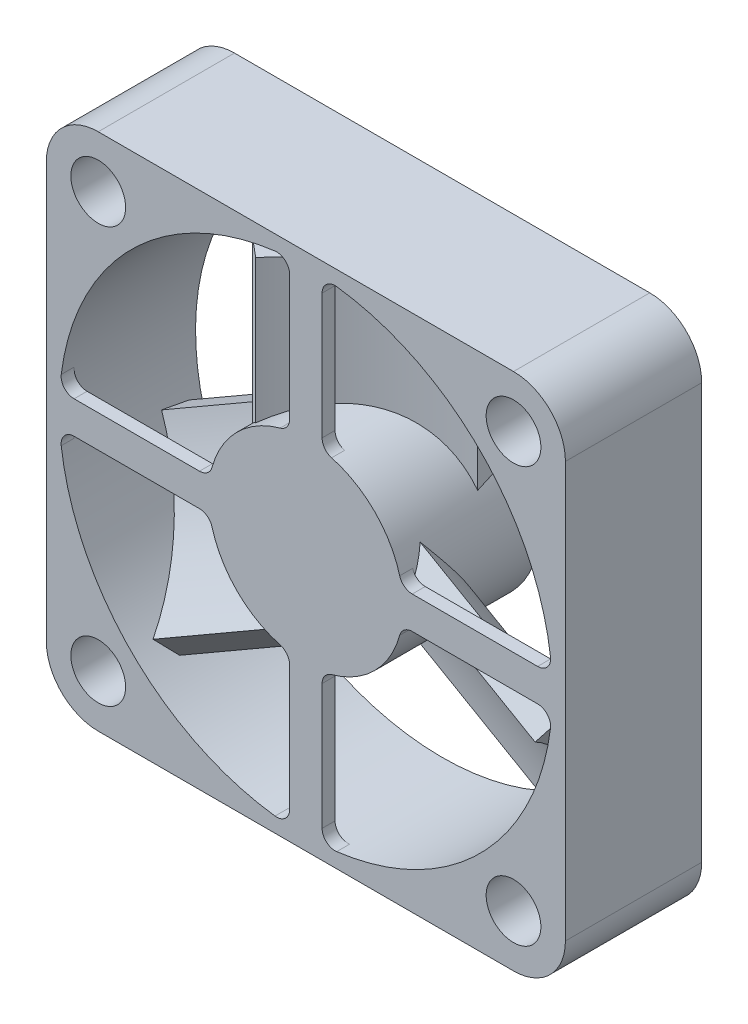
from build123d import *
from build123d.topology import SkipClean

# Parameters (mm, degrees)
SKETCH1_R           = 19
SKETCH1_R_2         = 2.11
BOSS_EXTRUDE1_DEPTH = 10.5
BOSS_EXTRUDE2_DEPTH = 1
CIRPATTERN1_COUNT   = 4
SKETCH4_R           = 7.5
BOSS_EXTRUDE3_DEPTH = 9.5
EXTRUDE_THIN1_DEPTH = 17
CIRPATTERN2_COUNT   = 3
CUT_EXTRUDE1_DEPTH  = 3.7
CIRPATTERN3_COUNT   = 4


with BuildPart() as part:
    # Sketch1 → Boss-Extrude1 (new body)
    with BuildSketch(Plane.XY):
        with BuildLine():
            Line((-16, 20), (16, 20))
            ThreePointArc((16, 20), (18.828427125, 18.828427125), (20, 16))
            Line((20, 16), (20, -16))
            ThreePointArc((20, -16), (18.828427125, -18.828427125), (16, -20))
            Line((16, -20), (-16, -20))
            ThreePointArc((-16, -20), (-18.828427125, -18.828427125), (-20, -16))
            Line((-20, -16), (-20, 16))
            ThreePointArc((-20, 16), (-18.828427125, 18.828427125), (-16, 20))
        make_face()
        Circle(SKETCH1_R, mode=Mode.SUBTRACT)
        with Locations((-16, 16)):
            Circle(SKETCH1_R_2, mode=Mode.SUBTRACT)
        with Locations((-16, -16)):
            Circle(SKETCH1_R_2, mode=Mode.SUBTRACT)
        with Locations((16, -16)):
            Circle(SKETCH1_R_2, mode=Mode.SUBTRACT)
        with Locations((16, 16)):
            Circle(SKETCH1_R_2, mode=Mode.SUBTRACT)
    extrude(amount=BOSS_EXTRUDE1_DEPTH)

    # Sketch2 → Boss-Extrude2 (add)
    with BuildSketch(Plane.XY.offset(10.5)):
        with BuildLine():
            Line((-1.25, 17.85882135), (-1.25, 8.196798155))
            ThreePointArc((-1.25, 8.196798155), (-1.454793774, 7.590459093), (-1.985294118, 7.232468961))
            ThreePointArc((-1.985294118, 7.232468961), (0, -7.5), (1.985294118, 7.232468961))
            ThreePointArc((1.985294118, 7.232468961), (1.454793774, 7.590459093), (1.25, 8.196798155))
            Line((1.25, 8.196798155), (1.25, 17.85882135))
            ThreePointArc((1.25, 17.85882135), (1.588562172, 18.60882135), (2.375, 18.850978091))
            ThreePointArc((2.375, 18.850978091), (0, 19), (-2.375, 18.850978091))
            ThreePointArc((-2.375, 18.850978091), (-1.588562172, 18.60882135), (-1.25, 17.85882135))
        make_face()
    boss_extrude2 = extrude(amount=-BOSS_EXTRUDE2_DEPTH)

    # CirPattern1: Boss-Extrude2 ×4 about axis
    cirpattern1_axis = Axis((0, 0, 0), (0, 0, 1))
    for i in range(1, CIRPATTERN1_COUNT):
        add(boss_extrude2.rotate(cirpattern1_axis, i * 360 / CIRPATTERN1_COUNT))

    # Sketch4 → Boss-Extrude3 (add)
    with SkipClean():  # keep this step's faces unmerged: merging them makes the solid invalid here
        with BuildSketch(Plane(origin=(0, 0, 9.5), x_dir=(-1, 0, 0), z_dir=(0, 0, -1))):
            with Locations(Location((0, 0, 0), (0, 0, 164.650522983))):  # turned: the seam where the file's is
                Circle(SKETCH4_R)
        extrude(amount=BOSS_EXTRUDE3_DEPTH)

    # Sketch5 → Extrude-Thin1 (add)
    with SkipClean():  # keep this step's faces unmerged: merging them makes the solid invalid here
        with BuildSketch(Plane(origin=(0, 0, 0), x_dir=(1, 0, 0), z_dir=(0, 1, 0))):
            with BuildLine():
                ThreePointArc((-6.073641938, -8.543547558), (-0.600270019, -4.001821599), (6.131264125, -1.705841866))
                Line((6.131264125, -1.705841866), (6.423685209, -3.684348857))
                ThreePointArc((6.423685209, -3.684348857), (0.377258659, -5.746653305), (-4.539056193, -9.826141254))
                Line((-4.539056193, -9.826141254), (-6.073641938, -8.543547558))
            make_face()
        extrude_thin1 = extrude(amount=EXTRUDE_THIN1_DEPTH)

    # CirPattern2: Extrude-Thin1 ×3 about axis
    with SkipClean():  # keep this step's faces unmerged: merging them makes the solid invalid here
        cirpattern2_axis = Axis((0, 0, 0), (0, 0, 1))
        for i in range(1, CIRPATTERN2_COUNT):
            add(extrude_thin1.rotate(cirpattern2_axis, i * 360 / CIRPATTERN2_COUNT))

    # Sketch6 → Cut-Extrude1 (cut)
    with SkipClean():  # keep this step's faces unmerged: merging them makes the solid invalid here
        with BuildSketch(Plane(origin=(0, 0, 0), x_dir=(-1, 0, 0), z_dir=(0, 0, -1))):
            Polygon((-16.896575472, 19.346065215), (-19.346065215, 16.896575472), (-18.449489743, 13.550510257), (-15.103424528, 12.653934785), (-12.653934785, 15.103424528), (-13.550510257, 18.449489743), align=None)
        cut_extrude1 = extrude(amount=-CUT_EXTRUDE1_DEPTH, mode=Mode.SUBTRACT)

    # CirPattern3: Cut-Extrude1 ×4 about axis
    with SkipClean():  # keep this step's faces unmerged: merging them makes the solid invalid here
        cirpattern3_axis = Axis((0, 0, 0), (0, 0, 1))
        for i in range(1, CIRPATTERN3_COUNT):
            add(cut_extrude1.rotate(cirpattern3_axis, i * 360 / CIRPATTERN3_COUNT), mode=Mode.SUBTRACT)


solid = part.part
